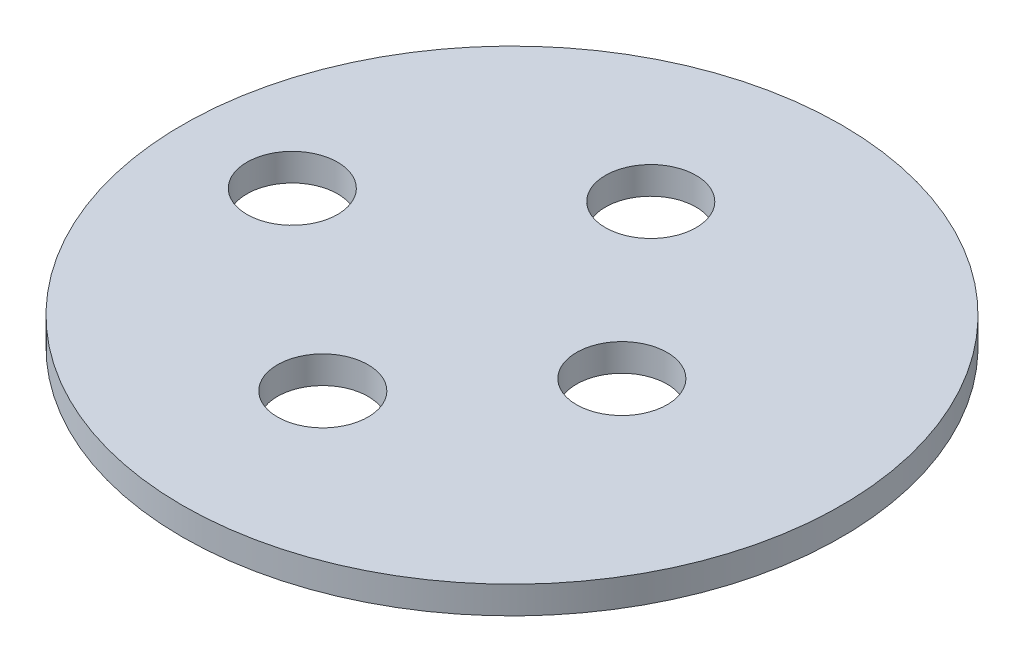
from build123d import *

# Parameters (mm, degrees)
SKETCH1_R           = 12
SKETCH1_R_2         = 1.65
BOSS_EXTRUDE1_DEPTH = 1


with BuildPart() as part:
    # Sketch1 → Boss-Extrude1 (new body)
    with BuildSketch(Plane(origin=(0, 0, 0), x_dir=(1, 0, 0), z_dir=(0, 1, 0))):
        with Locations((0.918840798, -0.637389416)):
            Circle(SKETCH1_R)
        with Locations((-0.138265228, 5.472098091)):
            Circle(SKETCH1_R_2, mode=Mode.SUBTRACT)
        with Locations((-0.138265228, -6.469943597)):
            Circle(SKETCH1_R_2, mode=Mode.SUBTRACT)
        with Locations((-7.081159202, -0.637389416)):
            Circle(SKETCH1_R_2, mode=Mode.SUBTRACT)
        with Locations((4.918840798, -0.637389416)):
            Circle(SKETCH1_R_2, mode=Mode.SUBTRACT)
    extrude(amount=-BOSS_EXTRUDE1_DEPTH)


solid = part.part
